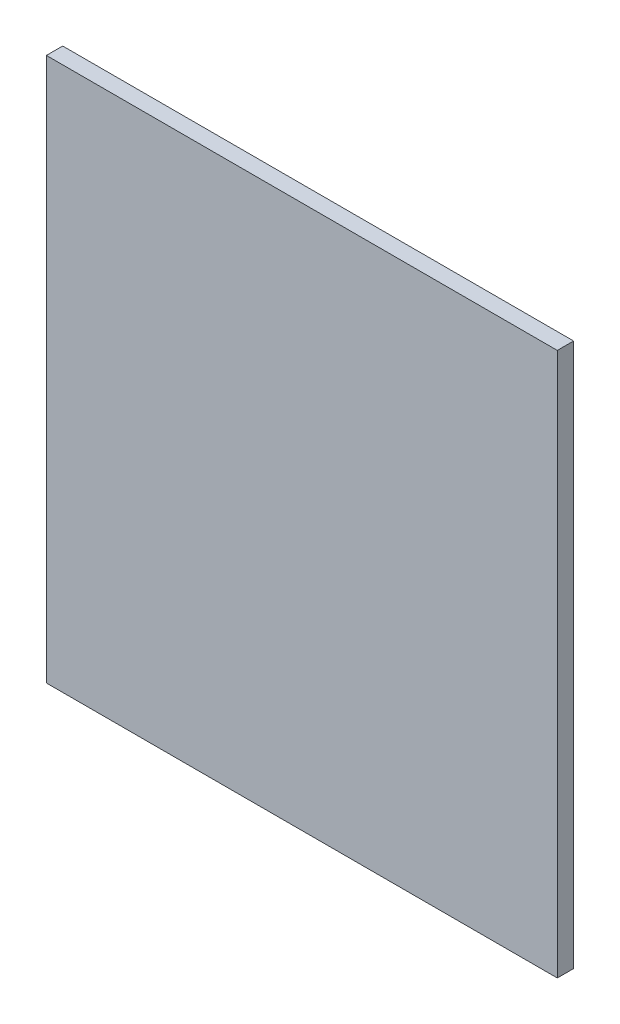
from build123d import *

# Parameters (mm, degrees)
SKETCH_1_W      = 564
SKETCH_1_H      = 600
EXTRUDE_1_DEPTH = 18


with BuildPart() as part:
    # Эскиз1 → Бобышка-Вытянуть1 (new body)
    with BuildSketch(Plane.XY):
        Rectangle(SKETCH_1_W, SKETCH_1_H)
    extrude(amount=EXTRUDE_1_DEPTH)


solid = part.part
